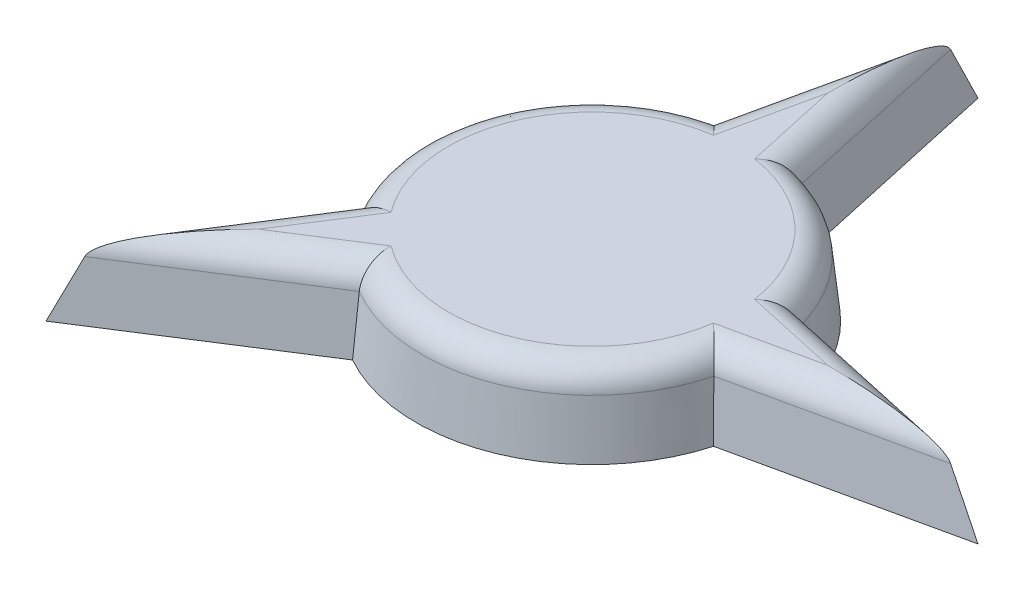
from build123d import *

# Parameters (mm, degrees)
BOSS_EXTRUDE1_DEPTH = 3
BOSS_EXTRUDE1_TAPER = 6
FILLET1_R           = 1


with BuildPart() as part:
    # Sketch2 → Boss-Extrude1 (new body)
    with BuildSketch(Plane(origin=(0, 0, 0), x_dir=(1, 0, 0), z_dir=(0, 1, 0))):
        with BuildLine():
            Line((1.794958228, 6.376825284), (0, 14.54359673))
            Line((0, 14.54359673), (-1.794958228, 6.376825284))
            ThreePointArc((-1.794958228, 6.376825284), (-6.120363771, 2.535137681), (-5.778323536, -3.239869266))
            Line((-5.778323536, -3.239869266), (-10.283875871, -10.283875871))
            Line((-10.283875871, -10.283875871), (-3.239869266, -5.778323536))
            ThreePointArc((-3.239869266, -5.778323536), (2.535137681, -6.120363771), (6.376825284, -1.794958228))
            Line((6.376825284, -1.794958228), (14.54359673, 0))
            Line((14.54359673, 0), (6.376825284, 1.794958228))
            ThreePointArc((6.376825284, 1.794958228), (4.68432363, 4.68432363), (1.794958228, 6.376825284))
        make_face()
    extrude(amount=BOSS_EXTRUDE1_DEPTH, taper=BOSS_EXTRUDE1_TAPER)

    # Fillet1
    fillet1_edges = [part.edges().sort_by_distance(p)[0] for p in [
        (-5.829052816, 3, -2.414472732),
        (-0.764125431, 3, -9.598084382),
        (0.764125431, 3, -9.598084382),
        (4.461363878, 3, -4.461363878),
        (9.598084382, 3, -0.764125431),
        (9.598084382, 3, 0.764125431),
        (2.414472732, 3, 5.829052816),
        (-6.246552279, 3, 7.327188827),
        (-7.327188827, 3, 6.246552279),
    ]]
    fillet(fillet1_edges, radius=FILLET1_R)


solid = part.part
